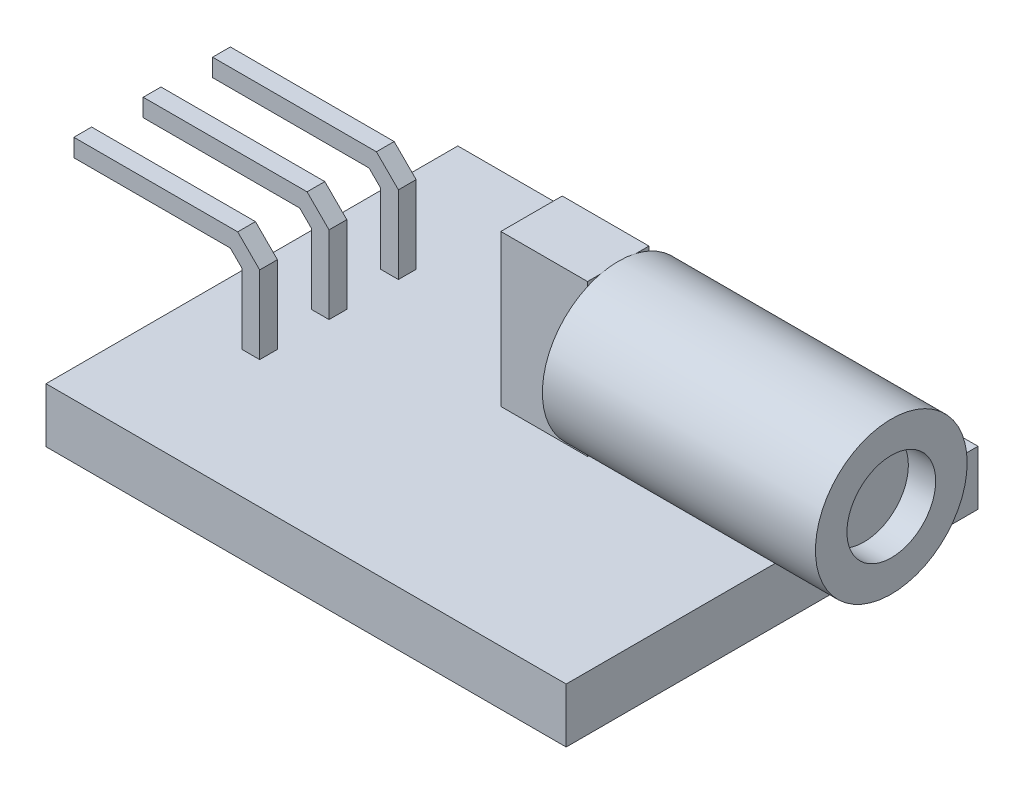
from build123d import *

# Parameters (mm, degrees)
SKETCH1_W               = 19.05
SKETCH1_H               = 15.08125
BOARD_DEPTH             = 2
SKETCH2_R               = 2.778125
LASERBARREL_DEPTH       = 10
SKETCH4_W               = 2.25
SKETCH4_H               = 5.55
BARREL_BUTT_MOUNT_DEPTH = 3.175
BOSS_EXTRUDE1_DEPTH     = 0.325
LPATTERN1_COUNT         = 2
LPATTERN1_PITCH         = 2.54
LPATTERN1_COUNT_DIR2    = 2
LPATTERN1_PITCH_DIR2    = 2.54
SKETCH6_R               = 1.625
CUT_EXTRUDE1_DEPTH      = 1


with BuildPart() as part:
    # Sketch1 → Board (new body)
    with BuildSketch(Plane(origin=(0, 0, 0), x_dir=(1, 0, 0), z_dir=(0, 1, 0))):
        Rectangle(SKETCH1_W, SKETCH1_H)
    extrude(amount=BOARD_DEPTH)



with BuildPart() as body_2:
    # Sketch2 → LaserBarrel (new body)
    with BuildSketch(Plane(origin=(12.7, 0, 0), x_dir=(0, 0, -1), z_dir=(1, 0, 0))):
        with Locations((1.190625, 4.85)):
            Circle(SKETCH2_R)
    extrude(amount=-LASERBARREL_DEPTH)


with BuildPart() as part_1:
    add(part.part)

    add(body_2.part)  # Barrel Butt Mount merges body 2
    # Sketch4 → Barrel Butt Mount (add)
    with BuildSketch(Plane.ZY.offset(-2.7)):
        with Locations((-1.190625, 4.775)):
            Rectangle(SKETCH4_W, SKETCH4_H)
    extrude(amount=BARREL_BUTT_MOUNT_DEPTH)

    # Sketch5 → Boss-Extrude1 (add, symmetric)
    with BuildSketch(Plane.XY):
        Polygon((-7.025, 2), (-6.375, 2), (-6.375, 4.844974747), (-7.180025253, 5.65), (-13.180025253, 5.65), (-13.180025253, 5), (-7.449264069, 5), (-7.025, 4.575735931), align=None)
    boss_extrude1 = extrude(amount=BOSS_EXTRUDE1_DEPTH, both=True)

    # LPattern1: Boss-Extrude1 2 × 2
    with Locations(*[Vector(0, 0, -1) * (i * LPATTERN1_PITCH) + Vector(0, 0, 1) * (j * LPATTERN1_PITCH_DIR2) for i in range(LPATTERN1_COUNT) for j in range(LPATTERN1_COUNT_DIR2) if (i, j) != (0, 0)]):
        add(boss_extrude1)

    # Sketch6 → Cut-Extrude1 (cut)
    with BuildSketch(Plane(origin=(12.7, 0, 0), x_dir=(0, 0, -1), z_dir=(1, 0, 0))):
        with Locations((1.190625, 4.85)):
            Circle(SKETCH6_R)
    extrude(amount=-CUT_EXTRUDE1_DEPTH, mode=Mode.SUBTRACT)


solid = part_1.part
